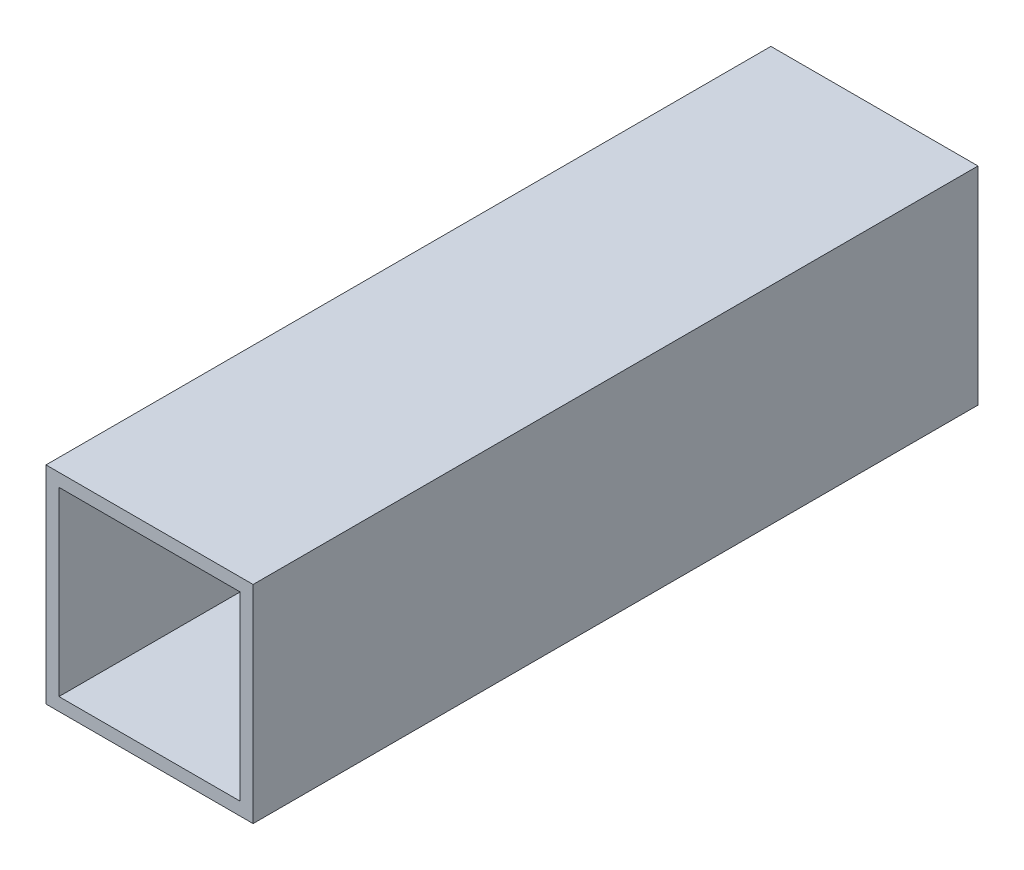
from build123d import *

# Parameters (mm, degrees)
SKETCH1_W           = 50.8
SKETCH1_H           = 50.8
SKETCH1_W_2         = 44.45
SKETCH1_H_2         = 44.45
BOSS_EXTRUDE1_DEPTH = 177.8


with BuildPart() as part:
    # Sketch1 → Boss-Extrude1 (new body)
    with BuildSketch(Plane.XY):
        with Locations((25.4, 25.4)):
            Rectangle(SKETCH1_W, SKETCH1_H)
        with Locations((25.4, 25.4)):
            Rectangle(SKETCH1_W_2, SKETCH1_H_2, mode=Mode.SUBTRACT)
    extrude(amount=BOSS_EXTRUDE1_DEPTH)


solid = part.part
